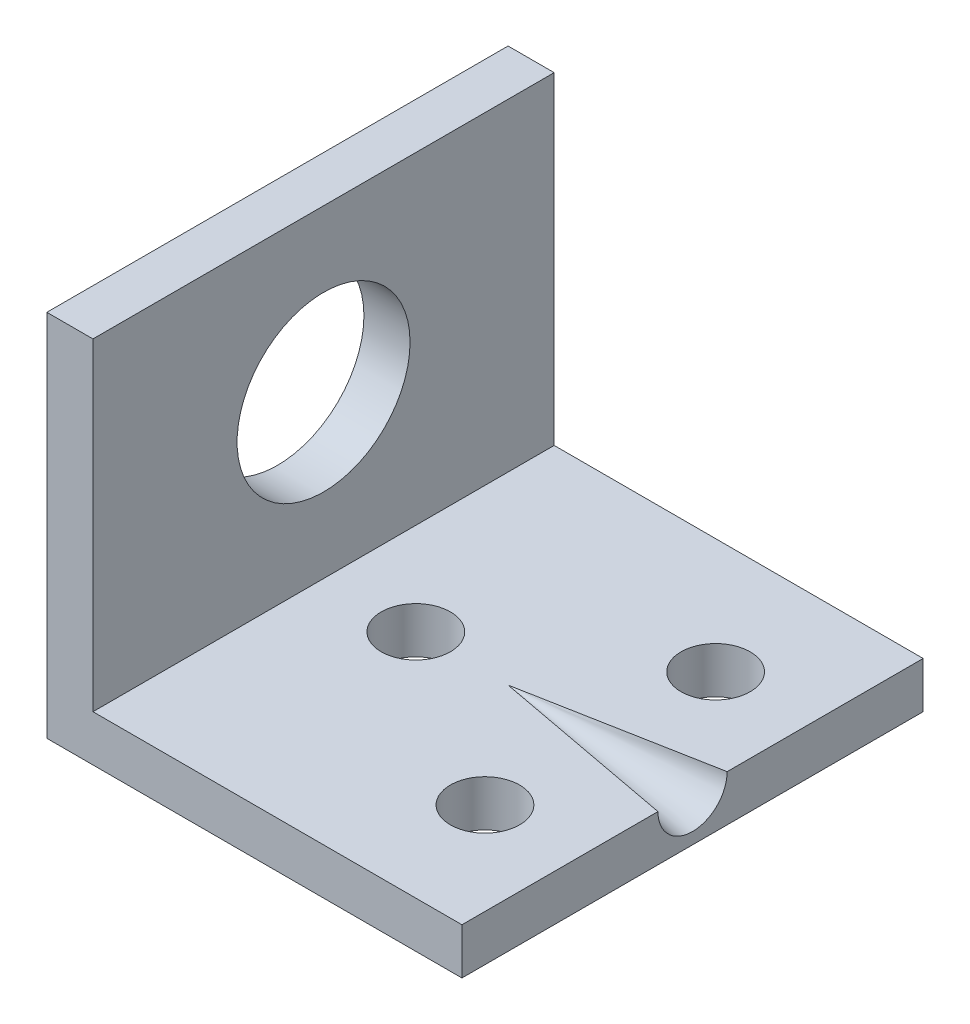
from build123d import *

# Parameters (mm, degrees)
SKETCH_1_R          = 1.5
EXTRUDE_1_DEPTH     = 2
SKETCH_2_W          = 2
SKETCH_2_H          = 20
EXTRUDE_2_DEPTH     = 14
SKETCH_4_R          = 3.75
CUT_EXTRUDE_1_DEPTH = 10


with BuildPart() as part:
    # 草图1 → 凸台-拉伸1 (new body)
    with BuildSketch(Plane(origin=(0, 0, 0), x_dir=(1, 0, 0), z_dir=(0, 1, 0))):
        Polygon((-3, 0), (-3, -10), (15, -10), (15, 10), (-3, 10), align=None)
        with Locations((3, 0)):
            Circle(SKETCH_1_R, mode=Mode.SUBTRACT)
        with Locations((11, 5)):
            Circle(SKETCH_1_R, mode=Mode.SUBTRACT)
        with Locations((11, -5)):
            Circle(SKETCH_1_R, mode=Mode.SUBTRACT)
    extrude(amount=EXTRUDE_1_DEPTH)

    # 草图2 → 凸台-拉伸2 (add)
    with BuildSketch(Plane(origin=(0, 2, 0), x_dir=(1, 0, 0), z_dir=(0, 1, 0))):
        with Locations((-2, 0)):
            Rectangle(SKETCH_2_W, SKETCH_2_H)
    extrude(amount=EXTRUDE_2_DEPTH)

    # 草图4 → 切除-拉伸1 (cut)
    with BuildSketch(Plane(origin=(-1, 0, 0), x_dir=(0, 0, -1), z_dir=(1, 0, 0))):
        with Locations((0, 9)):
            Circle(SKETCH_4_R)
    extrude(amount=-CUT_EXTRUDE_1_DEPTH, mode=Mode.SUBTRACT)

    # 草图7 → 切除-旋转1 (revolve, cut)
    with BuildSketch(Plane(origin=(0, 2, 0), x_dir=(1, 0, 0), z_dir=(0, 1, 0))):
        Polygon((7, 0), (15, 0), (15, 1.5), align=None)
    revolve(axis=Axis((7, 2, 0), (1, 0, 0)), mode=Mode.SUBTRACT)


solid = part.part
